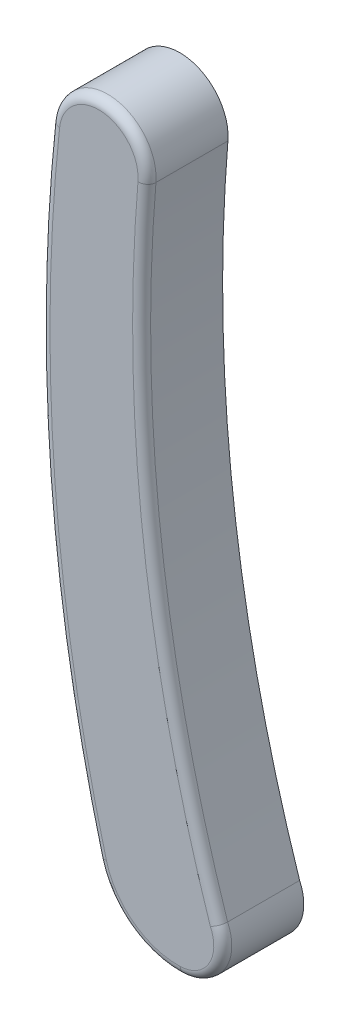
from build123d import *

# Parameters (mm, degrees)
EXTRUDE1_DEPTH = 4.5
FILLET1_R      = 0.5


with BuildPart() as part:
    # Sketch1 → Extrude1 (new body)
    with BuildSketch(Plane.XY):
        with BuildLine():
            ThreePointArc((0.835946957, 17.068293658), (-1.585758315, 19.967494126), (-4.513227009, 17.580037985))
            ThreePointArc((-4.513227009, 17.580037985), (-4.777050033, 0.394283137), (-1.899392561, -16.550889029))
            ThreePointArc((-1.899392561, -16.550889029), (-0.196852221, -19.065259749), (2.699402745, -19.9776253))
            ThreePointArc((2.699402745, -19.9776253), (4.693192511, -18.821786668), (4.819280406, -16.520642949))
            ThreePointArc((4.819280406, -16.520642949), (1.128455685, 0.072321122), (0.835946957, 17.068293658))
        make_face()
    extrude(amount=EXTRUDE1_DEPTH)

    # Fillet1
    fillet1_edges = [part.edges().sort_by_distance(p)[0] for p in [
        (-4.777050033, 0.394283137, 4.5),
        (-0.196852221, -19.065259749, 4.5),
        (4.693192511, -18.821786668, 4.5),
        (1.128455685, 0.072321122, 4.5),
        (-1.585758315, 19.967494126, 4.5),
    ]]
    fillet(fillet1_edges, radius=FILLET1_R)


solid = part.part
